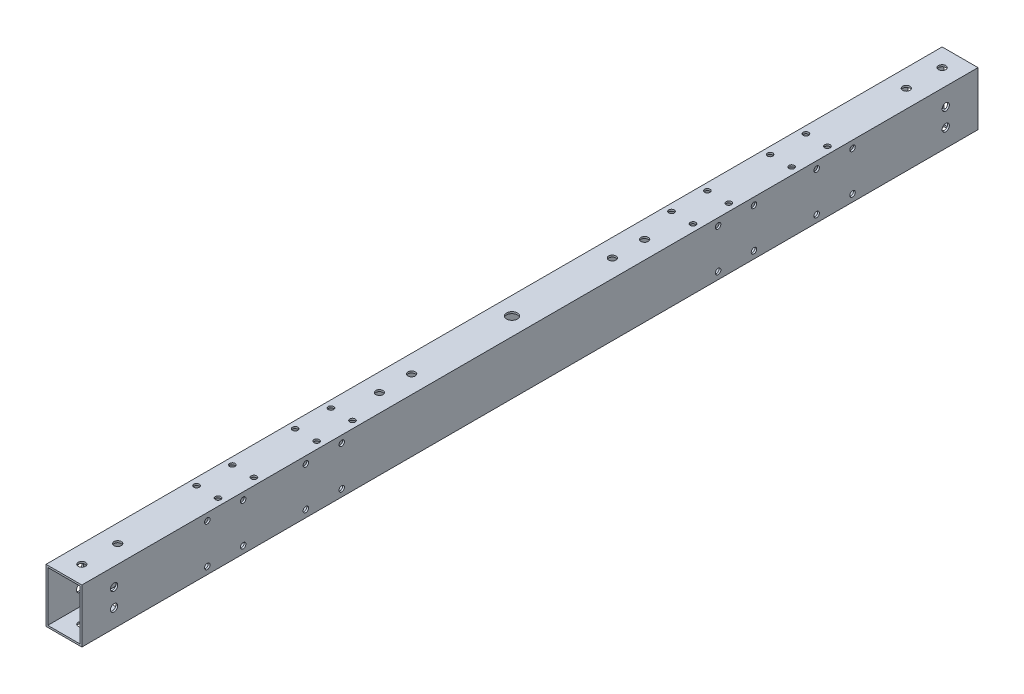
from build123d import *

# Parameters (mm, degrees)
SKETCH_1_W               = 20
SKETCH_1_H               = 30
SKETCH_1_W_2             = 18
SKETCH_1_H_2             = 28
EXTRUDE_1_DEPTH          = 250
SKETCH_2_R               = 2.025
CUT_EXTRUDE_1_DEPTH      = 30
SKETCH_3_R               = 6
CUT_EXTRUDE_2_DEPTH      = 10
SKETCH_4_R               = 3
CUT_EXTRUDE_3_DEPTH      = 10
SKETCH_5_R               = 2.025
CUT_EXTRUDE_4_DEPTH      = 50
SKETCH_6_R               = 3.75
CUT_EXTRUDE_5_DEPTH      = 2
SKETCH_7_R               = 1.525
CUT_EXTRUDE_6_DEPTH      = 10
SKETCH_8_R               = 1.525
CUT_EXTRUDE_7_DEPTH      = 10
MIRROR_2_COPY_1_SKETCH_R = 1.525
MIRROR_2_COPY_1_DEPTH    = 10
MIRROR_2_COPY_2_SKETCH_R = 1.525
MIRROR_2_COPY_2_DEPTH    = 10
MIRROR_3_COPY_1_SKETCH_R = 1.525
MIRROR_3_COPY_1_DEPTH    = 10
MIRROR_3_COPY_2_SKETCH_R = 1.525
MIRROR_3_COPY_2_DEPTH    = 10
MIRROR_3_COPY_3_SKETCH_R = 1.525
MIRROR_3_COPY_3_DEPTH    = 10
MIRROR_3_COPY_4_SKETCH_R = 1.525
MIRROR_3_COPY_4_DEPTH    = 10
MIRROR_3_COPY_5_SKETCH_R = 1.525
MIRROR_3_COPY_5_DEPTH    = 10
MIRROR_3_COPY_6_SKETCH_R = 1.525
MIRROR_3_COPY_6_DEPTH    = 10
CUT_EXTRUDE_8_DEPTH      = 10
SKETCH_11_R              = 2.475
CUT_EXTRUDE_9_DEPTH      = 10
SKETCH_12_R              = 2.025
CUT_EXTRUDE_10_DEPTH     = 20


with BuildPart() as part:
    # Sketch 1 → Extrude 1 (new body, symmetric)
    with BuildSketch(Plane.XY):
        Rectangle(SKETCH_1_W, SKETCH_1_H)
        Rectangle(SKETCH_1_W_2, SKETCH_1_H_2, mode=Mode.SUBTRACT)
    extrude(amount=EXTRUDE_1_DEPTH, both=True)

    # Sketch 2 → Cut-Extrude 1 (cut)
    with BuildSketch(Plane(origin=(0, 15, 0), x_dir=(1, 0, 0), z_dir=(0, 1, 0))):
        with Locations((0, -240)):
            Circle(SKETCH_2_R)
        with Locations((0, -220)):
            Circle(SKETCH_2_R)
        with Locations((0, 240)):
            Circle(SKETCH_2_R)
        with Locations((0, 220)):
            Circle(SKETCH_2_R)
    extrude(amount=-CUT_EXTRUDE_1_DEPTH, mode=Mode.SUBTRACT)

    # Sketch 3 → Cut-Extrude 2 (cut)
    with BuildSketch(Plane.XZ.offset(15)):
        Circle(SKETCH_3_R)
    extrude(amount=-CUT_EXTRUDE_2_DEPTH, mode=Mode.SUBTRACT)

    # Sketch 4 → Cut-Extrude 3 (cut)
    with BuildSketch(Plane.XZ.offset(-14)):
        Circle(SKETCH_4_R)
    extrude(amount=-CUT_EXTRUDE_3_DEPTH, mode=Mode.SUBTRACT)

    # Sketch 5 → Cut-Extrude 4 (cut)
    with BuildSketch(Plane.XZ.offset(15)):
        with Locations((0, 56)):
            Circle(SKETCH_5_R)
        with Locations((0, 74)):
            Circle(SKETCH_5_R)
        with Locations((0, -74)):
            Circle(SKETCH_5_R)
        with Locations((0, -56)):
            Circle(SKETCH_5_R)
    extrude(amount=-CUT_EXTRUDE_4_DEPTH, mode=Mode.SUBTRACT)

    # Sketch 6 → Cut-Extrude 5 (cut)
    with BuildSketch(Plane.XZ.offset(15)):
        with Locations((0, 74)):
            Circle(SKETCH_6_R)
        with Locations((0, 56)):
            Circle(SKETCH_6_R)
        with Locations((0, -56)):
            Circle(SKETCH_6_R)
        with Locations((0, -74)):
            Circle(SKETCH_6_R)
    extrude(amount=-CUT_EXTRUDE_5_DEPTH, mode=Mode.SUBTRACT)

    # Sketch 7 → Cut-Extrude 6 (cut)
    with BuildSketch(Plane(origin=(0, 15, 0), x_dir=(1, 0, 0), z_dir=(0, 1, 0))):
        with Locations((6, 115)):
            Circle(SKETCH_7_R)
        with Locations((6, 95)):
            Circle(SKETCH_7_R)
        with Locations((6, 150)):
            Circle(SKETCH_7_R)
        with Locations((6, 170)):
            Circle(SKETCH_7_R)
    cut_extrude_6 = extrude(amount=-CUT_EXTRUDE_6_DEPTH, mode=Mode.SUBTRACT)

    # Sketch 8 → Cut-Extrude 7 (cut)
    with BuildSketch(Plane(origin=(10, 0, 0), x_dir=(0, 0, -1), z_dir=(1, 0, 0))):
        with Locations((105, 11)):
            Circle(SKETCH_8_R)
        with Locations((125, 11)):
            Circle(SKETCH_8_R)
        with Locations((160, 11)):
            Circle(SKETCH_8_R)
        with Locations((180, 11)):
            Circle(SKETCH_8_R)
    cut_extrude_7 = extrude(amount=-CUT_EXTRUDE_7_DEPTH, mode=Mode.SUBTRACT)

    # Mirror 1: Cut-Extrude 6, Cut-Extrude 7 across plane
    add(cut_extrude_6.mirror(Plane.ZX), mode=Mode.SUBTRACT)
    add(cut_extrude_7.mirror(Plane.ZX), mode=Mode.SUBTRACT)

    # Mirror 2: Cut-Extrude 6, Cut-Extrude 7 across plane
    add(cut_extrude_6.mirror(Plane.XY), mode=Mode.SUBTRACT)
    add(cut_extrude_7.mirror(Plane.XY), mode=Mode.SUBTRACT)

    # Mirror 2 copy 1 sketch → Mirror 2 copy 1 (cut)
    with BuildSketch(Plane.XZ.offset(15)):
        with Locations((6, 115)):
            Circle(MIRROR_2_COPY_1_SKETCH_R)
        with Locations((6, 95)):
            Circle(MIRROR_2_COPY_1_SKETCH_R)
        with Locations((6, 150)):
            Circle(MIRROR_2_COPY_1_SKETCH_R)
        with Locations((6, 170)):
            Circle(MIRROR_2_COPY_1_SKETCH_R)
    extrude(amount=-MIRROR_2_COPY_1_DEPTH, mode=Mode.SUBTRACT)

    # Mirror 2 copy 2 sketch → Mirror 2 copy 2 (cut)
    with BuildSketch(Plane(origin=(10, 0, 0), x_dir=(0, 0, 1), z_dir=(1, 0, 0))):
        with Locations((105, 11)):
            Circle(MIRROR_2_COPY_2_SKETCH_R)
        with Locations((125, 11)):
            Circle(MIRROR_2_COPY_2_SKETCH_R)
        with Locations((160, 11)):
            Circle(MIRROR_2_COPY_2_SKETCH_R)
        with Locations((180, 11)):
            Circle(MIRROR_2_COPY_2_SKETCH_R)
    extrude(amount=-MIRROR_2_COPY_2_DEPTH, mode=Mode.SUBTRACT)

    # Mirror 3: Cut-Extrude 6, Cut-Extrude 7 across plane
    add(cut_extrude_6.mirror(Plane(origin=(0, 0, 0), x_dir=(0, 0, 1), z_dir=(1, 0, 0))), mode=Mode.SUBTRACT)
    add(cut_extrude_7.mirror(Plane(origin=(0, 0, 0), x_dir=(0, 0, 1), z_dir=(1, 0, 0))), mode=Mode.SUBTRACT)

    # Mirror 3 copy 1 sketch → Mirror 3 copy 1 (cut)
    with BuildSketch(Plane(origin=(0, 15, 0), x_dir=(-1, 0, 0), z_dir=(0, 1, 0))):
        with Locations((6, 115)):
            Circle(MIRROR_3_COPY_1_SKETCH_R)
        with Locations((6, 95)):
            Circle(MIRROR_3_COPY_1_SKETCH_R)
        with Locations((6, 150)):
            Circle(MIRROR_3_COPY_1_SKETCH_R)
        with Locations((6, 170)):
            Circle(MIRROR_3_COPY_1_SKETCH_R)
    extrude(amount=-MIRROR_3_COPY_1_DEPTH, mode=Mode.SUBTRACT)

    # Mirror 3 copy 2 sketch → Mirror 3 copy 2 (cut)
    with BuildSketch(Plane.ZY.offset(10)):
        with Locations((105, 11)):
            Circle(MIRROR_3_COPY_2_SKETCH_R)
        with Locations((125, 11)):
            Circle(MIRROR_3_COPY_2_SKETCH_R)
        with Locations((160, 11)):
            Circle(MIRROR_3_COPY_2_SKETCH_R)
        with Locations((180, 11)):
            Circle(MIRROR_3_COPY_2_SKETCH_R)
    extrude(amount=-MIRROR_3_COPY_2_DEPTH, mode=Mode.SUBTRACT)

    # Mirror 3 copy 3 sketch → Mirror 3 copy 3 (cut)
    with BuildSketch(Plane(origin=(0, -15, 0), x_dir=(-1, 0, 0), z_dir=(0, -1, 0))):
        with Locations((6, -115)):
            Circle(MIRROR_3_COPY_3_SKETCH_R)
        with Locations((6, -95)):
            Circle(MIRROR_3_COPY_3_SKETCH_R)
        with Locations((6, -150)):
            Circle(MIRROR_3_COPY_3_SKETCH_R)
        with Locations((6, -170)):
            Circle(MIRROR_3_COPY_3_SKETCH_R)
    extrude(amount=-MIRROR_3_COPY_3_DEPTH, mode=Mode.SUBTRACT)

    # Mirror 3 copy 4 sketch → Mirror 3 copy 4 (cut)
    with BuildSketch(Plane.ZY.offset(10)):
        with Locations((105, -11)):
            Circle(MIRROR_3_COPY_4_SKETCH_R)
        with Locations((125, -11)):
            Circle(MIRROR_3_COPY_4_SKETCH_R)
        with Locations((160, -11)):
            Circle(MIRROR_3_COPY_4_SKETCH_R)
        with Locations((180, -11)):
            Circle(MIRROR_3_COPY_4_SKETCH_R)
    extrude(amount=-MIRROR_3_COPY_4_DEPTH, mode=Mode.SUBTRACT)

    # Mirror 3 copy 5 sketch → Mirror 3 copy 5 (cut)
    with BuildSketch(Plane(origin=(0, -15, 0), x_dir=(-1, 0, 0), z_dir=(0, -1, 0))):
        with Locations((6, 115)):
            Circle(MIRROR_3_COPY_5_SKETCH_R)
        with Locations((6, 95)):
            Circle(MIRROR_3_COPY_5_SKETCH_R)
        with Locations((6, 150)):
            Circle(MIRROR_3_COPY_5_SKETCH_R)
        with Locations((6, 170)):
            Circle(MIRROR_3_COPY_5_SKETCH_R)
    extrude(amount=-MIRROR_3_COPY_5_DEPTH, mode=Mode.SUBTRACT)

    # Mirror 3 copy 6 sketch → Mirror 3 copy 6 (cut)
    with BuildSketch(Plane(origin=(-10, 0, 0), x_dir=(0, 0, -1), z_dir=(-1, 0, 0))):
        with Locations((105, 11)):
            Circle(MIRROR_3_COPY_6_SKETCH_R)
        with Locations((125, 11)):
            Circle(MIRROR_3_COPY_6_SKETCH_R)
        with Locations((160, 11)):
            Circle(MIRROR_3_COPY_6_SKETCH_R)
        with Locations((180, 11)):
            Circle(MIRROR_3_COPY_6_SKETCH_R)
    extrude(amount=-MIRROR_3_COPY_6_DEPTH, mode=Mode.SUBTRACT)

    # Sketch 9 → Cut-Extrude 8 (cut)
    with BuildSketch(Plane.XZ.offset(15)):
        with BuildLine():
            Line((6, 12.5), (6, -12.5))
            ThreePointArc((6, -12.5), (0, -18.5), (-6, -12.5))
            Line((-6, -12.5), (-6, 12.5))
            ThreePointArc((-6, 12.5), (0, 18.5), (6, 12.5))
        make_face()
    extrude(amount=-CUT_EXTRUDE_8_DEPTH, mode=Mode.SUBTRACT)

    # Sketch 11 → Cut-Extrude 9 (cut)
    with BuildSketch(Plane.XZ.offset(15)):
        with Locations((0, 25)):
            Circle(SKETCH_11_R)
        with Locations((0, -25)):
            Circle(SKETCH_11_R)
    extrude(amount=-CUT_EXTRUDE_9_DEPTH, mode=Mode.SUBTRACT)

    # Sketch 12 → Cut-Extrude 10 (cut)
    with BuildSketch(Plane(origin=(10, 0, 0), x_dir=(0, 0, -1), z_dir=(1, 0, 0))):
        with Locations((-232, 5)):
            Circle(SKETCH_12_R)
        with Locations((-232, -5)):
            Circle(SKETCH_12_R)
        with Locations((232, -5)):
            Circle(SKETCH_12_R)
        with Locations((232, 5)):
            Circle(SKETCH_12_R)
    extrude(amount=-CUT_EXTRUDE_10_DEPTH, mode=Mode.SUBTRACT)


solid = part.part
